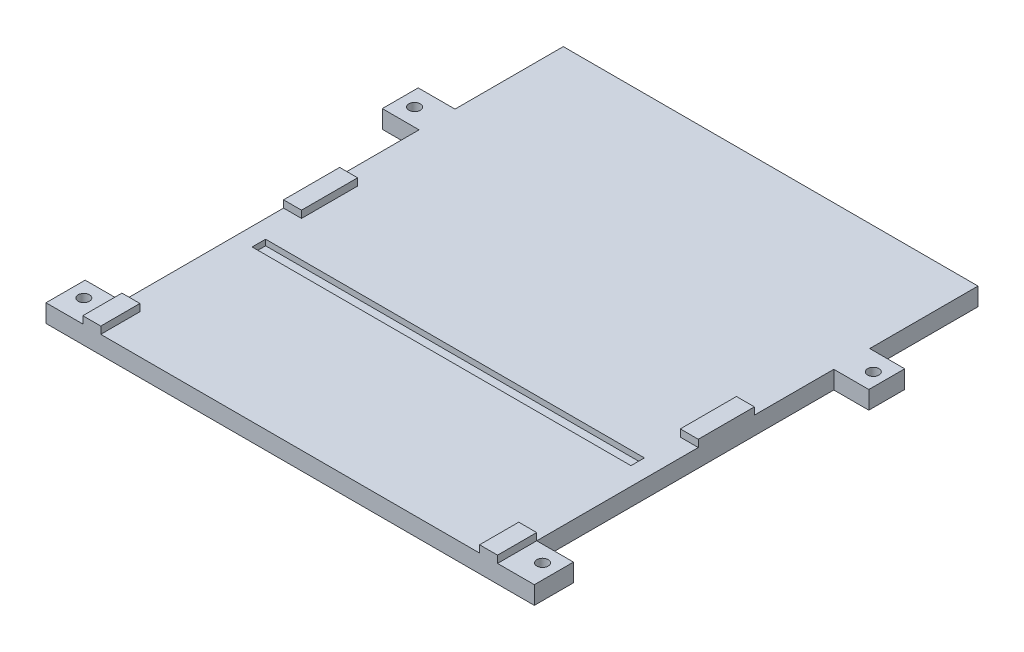
from build123d import *

# Parameters (mm, degrees)
SKETCH1_W           = 211
SKETCH1_H           = 110
BOSS_EXTRUDE1_DEPTH = 10
SKETCH1_3_W         = 10
SKETCH1_3_H         = 110
BOSS_EXTRUDE2_DEPTH = 14
SKETCH5_W           = 211
SKETCH5_H           = 7.5
CUT_EXTRUDE5_DEPTH  = 3.2
SKETCH6_R           = 3.15
BOSS_EXTRUDE3_DEPTH = 10
CUT_EXTRUDE9_DEPTH  = 2
SKETCH11_W          = 10
SKETCH11_H          = 21.813163886
BOSS_EXTRUDE5_DEPTH = 4
SKETCH12_W          = 10
SKETCH12_H          = 78.75
CUT_EXTRUDE10_DEPTH = 4
CUT_EXTRUDE7_DEPTH  = 3
SKETCH13_W          = 231
SKETCH13_H          = 60.312496228
BOSS_EXTRUDE6_DEPTH = 10


with BuildPart() as part:
    # Sketch1 → Boss-Extrude1 (new body)
    with BuildSketch(Plane(origin=(0, 0, 0), x_dir=(1, 0, 0), z_dir=(0, 1, 0))):
        Rectangle(SKETCH1_W, SKETCH1_H)
    extrude(amount=BOSS_EXTRUDE1_DEPTH)

    # Sketch1_3 → Boss-Extrude2 (add)
    with BuildSketch(Plane(origin=(0, 0, 0), x_dir=(1, 0, 0), z_dir=(0, 1, 0))):
        with Locations((-110.5, 0)):
            Rectangle(SKETCH1_3_W, SKETCH1_3_H)
        with Locations((110.5, 0)):
            Rectangle(SKETCH1_3_W, SKETCH1_3_H)
    extrude(amount=BOSS_EXTRUDE2_DEPTH)

    # Sketch5 → Cut-Extrude5 (cut)
    with BuildSketch(Plane(origin=(0, 10, 0), x_dir=(1, 0, 0), z_dir=(0, 1, 0))):
        Rectangle(SKETCH5_W, SKETCH5_H)
    extrude(amount=-CUT_EXTRUDE5_DEPTH, mode=Mode.SUBTRACT)

    # Sketch6 → Boss-Extrude3 (add)
    # profile 1 of 2: a face of its own
    with BuildSketch(Plane(origin=(0, 0, 0), x_dir=(1, 0, 0), z_dir=(0, 1, 0))):
        Polygon((-136, 119.243156134), (-106.5, 119.243156134), (104.5, 119.243156134), (135, 119.243156134), (135, 99.243156134), (115.5, 99.243156134), (115.5, 55), (-115.5, 55), (-115.5, 99.243156134), (-136, 99.243156134), align=None)
        with Locations((-127.75, 109)):
            Circle(SKETCH6_R, mode=Mode.SUBTRACT)
        with Locations((127.75, 109)):
            Circle(SKETCH6_R, mode=Mode.SUBTRACT)
    # profile 2 of 2: a face of its own
    with BuildSketch(Plane(origin=(0, 0, 0), x_dir=(1, 0, 0), z_dir=(0, 1, 0))):
        Polygon((-136, -66.252271661), (-115.5, -66.252271661), (-115.5, -55), (-104.100072783, -55), (104.5, -55), (115.5, -55), (115.5, -66.252271661), (136, -66.252271661), (136, -88.065435547), (-136, -88.065435547), align=None)
        with Locations((-127.75, -75.253909377)):
            Circle(SKETCH6_R, mode=Mode.SUBTRACT)
        with Locations((127.75, -75.253909377)):
            Circle(SKETCH6_R, mode=Mode.SUBTRACT)
    extrude(amount=BOSS_EXTRUDE3_DEPTH)

    # Sketch7_2 → Cut-Extrude9 (cut)
    with BuildSketch(Plane.XZ):
        Polygon((-127.75, 69.364936631), (-122.65, 72.309423004), (-122.65, 78.19839575), (-127.75, 81.142882123), (-132.85, 78.19839575), (-132.85, 72.309423004), align=None)
        Polygon((127.75, 69.364936631), (132.85, 72.309423004), (132.85, 78.19839575), (127.75, 81.142882123), (122.65, 78.19839575), (122.65, 72.309423004), align=None)
        Polygon((-127.75, -114.888972746), (-122.65, -111.944486373), (-122.65, -106.055513627), (-127.75, -103.111027254), (-132.85, -106.055513627), (-132.85, -111.944486373), align=None)
        Polygon((127.75, -114.888972746), (132.85, -111.944486373), (132.85, -106.055513627), (127.75, -103.111027254), (122.65, -106.055513627), (122.65, -111.944486373), align=None)
    extrude(amount=-CUT_EXTRUDE9_DEPTH, mode=Mode.SUBTRACT)

    # Sketch11 → Boss-Extrude5 (add)
    with BuildSketch(Plane(origin=(0, 10, 0), x_dir=(1, 0, 0), z_dir=(0, 1, 0))):
        with Locations((-110.5, -77.158853604)):
            Rectangle(SKETCH11_W, SKETCH11_H)
        with Locations((110.5, -77.158853604)):
            Rectangle(SKETCH11_W, SKETCH11_H)
    extrude(amount=BOSS_EXTRUDE5_DEPTH)

    # Sketch12 → Cut-Extrude10 (cut)
    with BuildSketch(Plane(origin=(0, 14, 0), x_dir=(1, 0, 0), z_dir=(0, 1, 0))):
        with Locations((-110.5, -15.625)):
            Rectangle(SKETCH12_W, SKETCH12_H)
        with Locations((110.5, -15.625)):
            Rectangle(SKETCH12_W, SKETCH12_H)
    extrude(amount=-CUT_EXTRUDE10_DEPTH, mode=Mode.SUBTRACT)

    # Sketch7 → Cut-Extrude7 (cut)
    with BuildSketch(Plane.XZ):
        Polygon((-127.75, 69.364936631), (-122.65, 72.309423004), (-122.65, 78.19839575), (-127.75, 81.142882123), (-132.85, 78.19839575), (-132.85, 72.309423004), align=None)
        Polygon((127.75, 69.364936631), (132.85, 72.309423004), (132.85, 78.19839575), (127.75, 81.142882123), (122.65, 78.19839575), (122.65, 72.309423004), align=None)
        Polygon((-127.75, -114.888972746), (-122.65, -111.944486373), (-122.65, -106.055513627), (-127.75, -103.111027254), (-132.85, -106.055513627), (-132.85, -111.944486373), align=None)
        Polygon((127.75, -114.888972746), (132.85, -111.944486373), (132.85, -106.055513627), (127.75, -103.111027254), (122.65, -106.055513627), (122.65, -111.944486373), align=None)
    extrude(amount=-CUT_EXTRUDE7_DEPTH, mode=Mode.SUBTRACT)

    # Sketch13 → Boss-Extrude6 (add)
    with BuildSketch(Plane(origin=(0, 0, 0), x_dir=(1, 0, 0), z_dir=(0, 1, 0))):
        with Locations((0, 149.399404248)):
            Rectangle(SKETCH13_W, SKETCH13_H)
    extrude(amount=BOSS_EXTRUDE6_DEPTH)


solid = part.part
